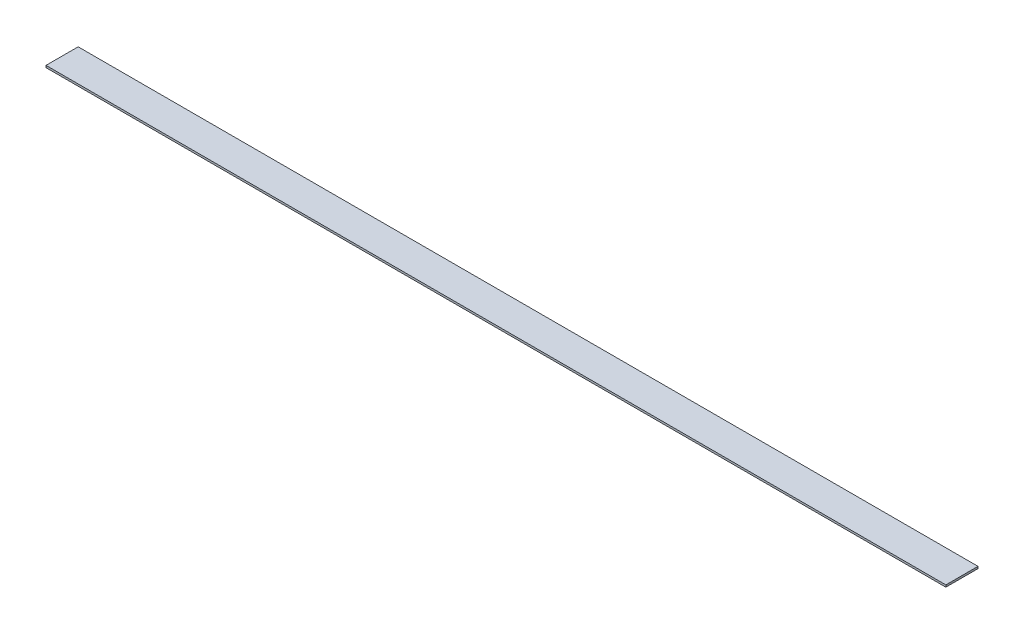
from build123d import *

# Parameters (mm, degrees)
SKETCH1_W           = 711.2
SKETCH1_H           = 25.4
BOSS_EXTRUDE1_DEPTH = 1.5875


with BuildPart() as part:
    # Sketch1 → Boss-Extrude1 (new body)
    with BuildSketch(Plane(origin=(0, 0, 0), x_dir=(1, 0, 0), z_dir=(0, 1, 0))):
        with Locations((355.6, 12.7)):
            Rectangle(SKETCH1_W, SKETCH1_H)
    extrude(amount=BOSS_EXTRUDE1_DEPTH)


solid = part.part
